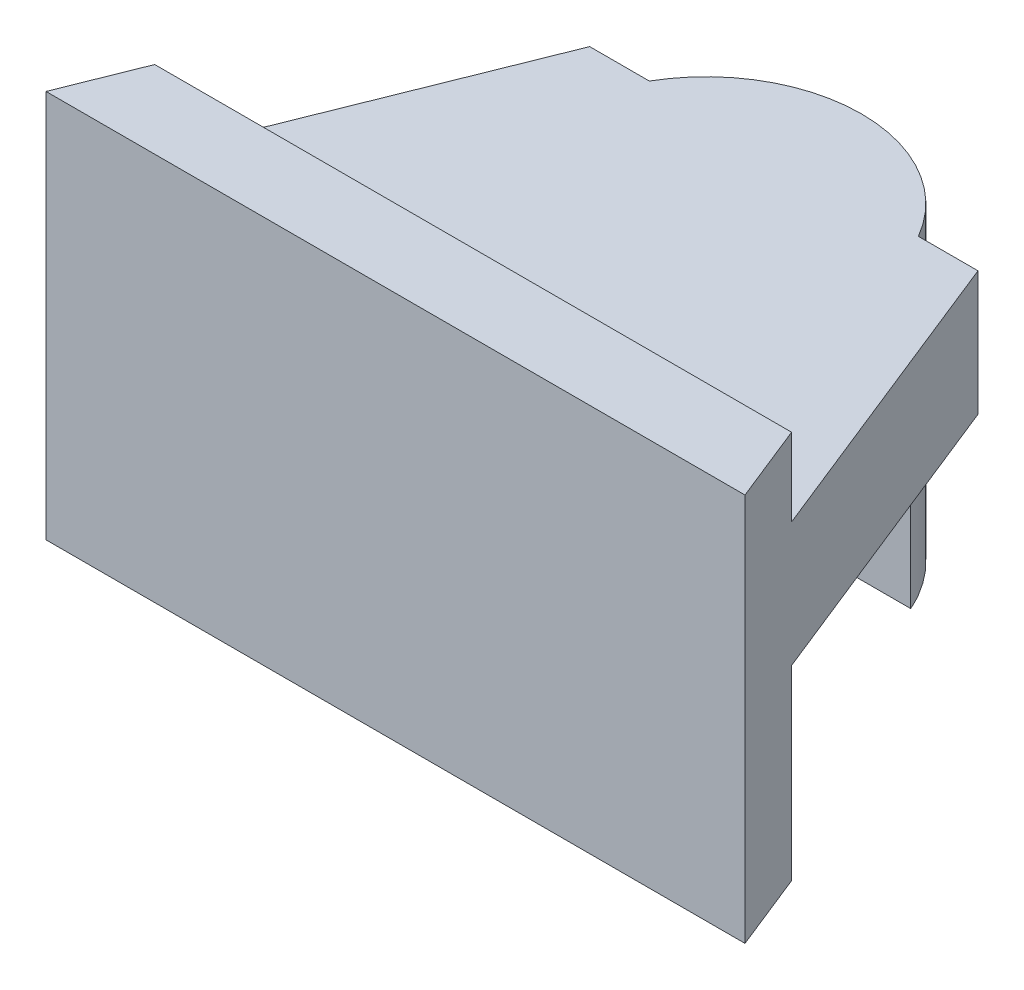
from build123d import *

# Parameters (mm, degrees)
SKETCH3_R           = 20
BOSS_EXTRUDE1_DEPTH = 40
BOSS_EXTRUDE2_START = -16
BOSS_EXTRUDE2_DEPTH = 16
BOSS_EXTRUDE3_START = -26
BOSS_EXTRUDE3_DEPTH = 50
BOSS_EXTRUDE4_START = 20
BOSS_EXTRUDE4_DEPTH = 20
CUT_EXTRUDE1_START  = 24
CUT_EXTRUDE1_DEPTH  = 12


with BuildPart() as part:
    # Sketch3 → Boss-Extrude1 (new body)
    with BuildSketch(Plane(origin=(0, 0, 0), x_dir=(1, 0, 0), z_dir=(0, 1, 0))):
        Circle(SKETCH3_R)
    extrude(amount=BOSS_EXTRUDE1_DEPTH)

    # Sketch4 → Boss-Extrude2 (add)
    with BuildSketch(Plane(origin=(0, 40, 0), x_dir=(1, 0, 0), z_dir=(0, 1, 0)).offset(BOSS_EXTRUDE2_START)):
        Polygon((25, 10), (45, -40), (-45, -40), (-25, 10), (-17.320508076, 10), (17.320508076, 10), align=None)
    extrude(amount=BOSS_EXTRUDE2_DEPTH)

    # Sketch6 → Boss-Extrude3 (add)
    with BuildSketch(Plane(origin=(0, 24, 0), x_dir=(-1, 0, 0), z_dir=(0, -1, 0)).offset(BOSS_EXTRUDE3_START)):
        Polygon((-41, -30), (41, -30), (45, -40), (-45, -40), align=None)
    extrude(amount=BOSS_EXTRUDE3_DEPTH)

    # Sketch7 → Boss-Extrude4 (add)
    with BuildSketch(Plane(origin=(0, 24, 0), x_dir=(-1, 0, 0), z_dir=(0, -1, 0)).offset(BOSS_EXTRUDE4_START)):
        with BuildLine():
            Line((-6, -19.078784028), (-6, -30))
            Line((-6, -30), (6, -30))
            Line((6, -30), (6, -19.078784028))
            ThreePointArc((6, -19.078784028), (0, -20), (-6, -19.078784028))
        make_face()
    extrude(amount=-BOSS_EXTRUDE4_DEPTH)

    # Sketch7_3 → Cut-Extrude1 (cut)
    with BuildSketch(Plane(origin=(0, 24, 0), x_dir=(-1, 0, 0), z_dir=(0, -1, 0)).offset(CUT_EXTRUDE1_START)):
        with BuildLine():
            ThreePointArc((-18.33030278, 8), (-20, 0), (-18.33030278, -8))
            Line((-18.33030278, -8), (18.33030278, -8))
            ThreePointArc((18.33030278, -8), (20, 0), (18.33030278, 8))
            Line((18.33030278, 8), (-18.33030278, 8))
        make_face()
    extrude(amount=-CUT_EXTRUDE1_DEPTH, mode=Mode.SUBTRACT)


solid = part.part
